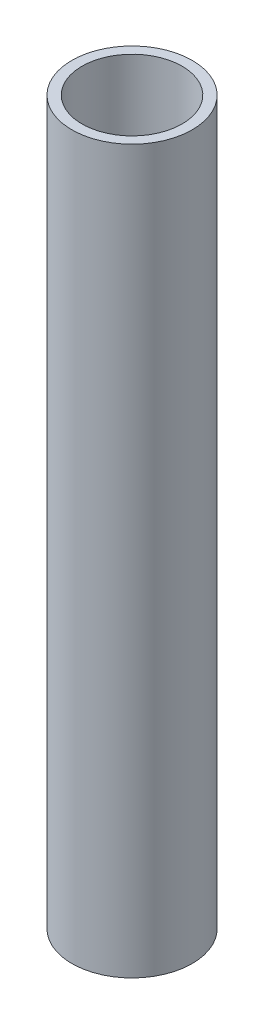
from build123d import *

# Parameters (mm, degrees)
SKETCH11_R              = 6.35
SKETCH11_R_2            = 5.2832
PIPE_0_5_SCH_40_1_DEPTH = 76.2


with BuildPart() as part:
    # Sketch11 → Pipe 0.5 SCH 40(1) (new body)
    with BuildSketch(Plane(origin=(0, -198.15032918, 277.294378666), x_dir=(0, 0, -1), z_dir=(0, -1, 0))):
        Circle(SKETCH11_R)
        Circle(SKETCH11_R_2, mode=Mode.SUBTRACT)
    extrude(amount=PIPE_0_5_SCH_40_1_DEPTH)


solid = part.part
